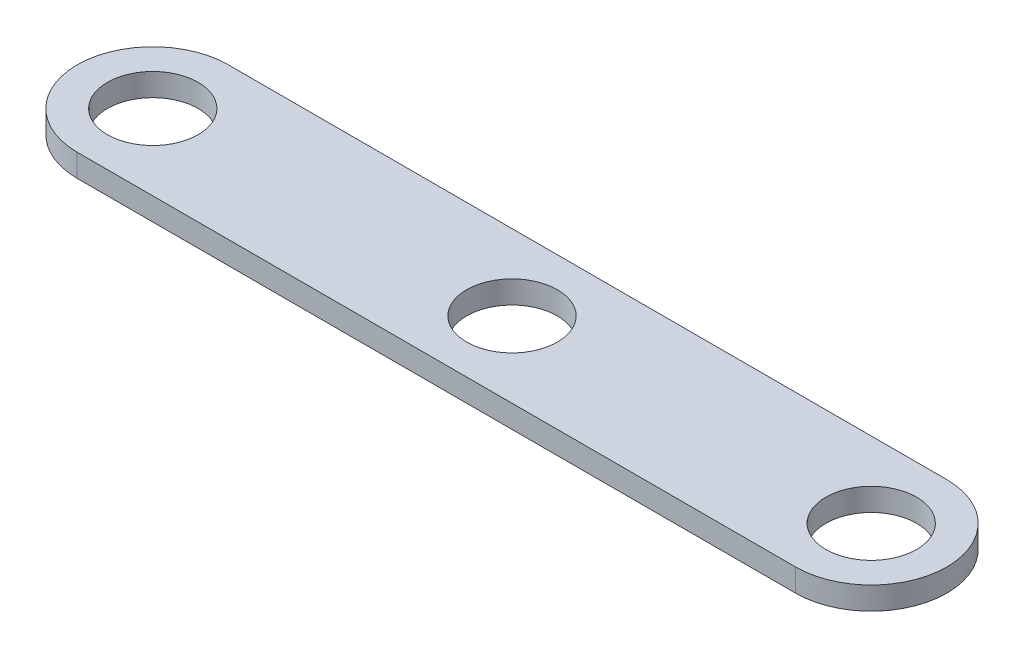
from build123d import *

# Parameters (mm, degrees)
SKETCH1_R           = 6
BOSS_EXTRUDE1_DEPTH = 3
SKETCH2_R           = 6
CUT_EXTRUDE1_DEPTH  = 4


with BuildPart() as part:
    # Sketch1 → Boss-Extrude1 (new body)
    with BuildSketch(Plane(origin=(0, 0, 0), x_dir=(1, 0, 0), z_dir=(0, 1, 0))):
        with BuildLine():
            Line((-7.092556659, 19.326923077), (87.907443341, 19.326923077))
            ThreePointArc((87.907443341, 19.326923077), (97.907443341, 9.326923077), (87.907443341, -0.673076923))
            Line((87.907443341, -0.673076923), (-7.092556659, -0.673076923))
            ThreePointArc((-7.092556659, -0.673076923), (-17.092556659, 9.326923077), (-7.092556659, 19.326923077))
        make_face()
        with Locations((-7.092556659, 9.326923077)):
            Circle(SKETCH1_R, mode=Mode.SUBTRACT)
        with Locations((87.907443341, 9.326923077)):
            Circle(SKETCH1_R, mode=Mode.SUBTRACT)
    extrude(amount=BOSS_EXTRUDE1_DEPTH)

    # Sketch2 → Cut-Extrude1 (cut, through all)
    with BuildSketch(Plane(origin=(0, 3, 0), x_dir=(1, 0, 0), z_dir=(0, 1, 0))):
        with Locations((40.407443341, 9.326923077)):
            Circle(SKETCH2_R)
    extrude(amount=-CUT_EXTRUDE1_DEPTH, mode=Mode.SUBTRACT)


solid = part.part
